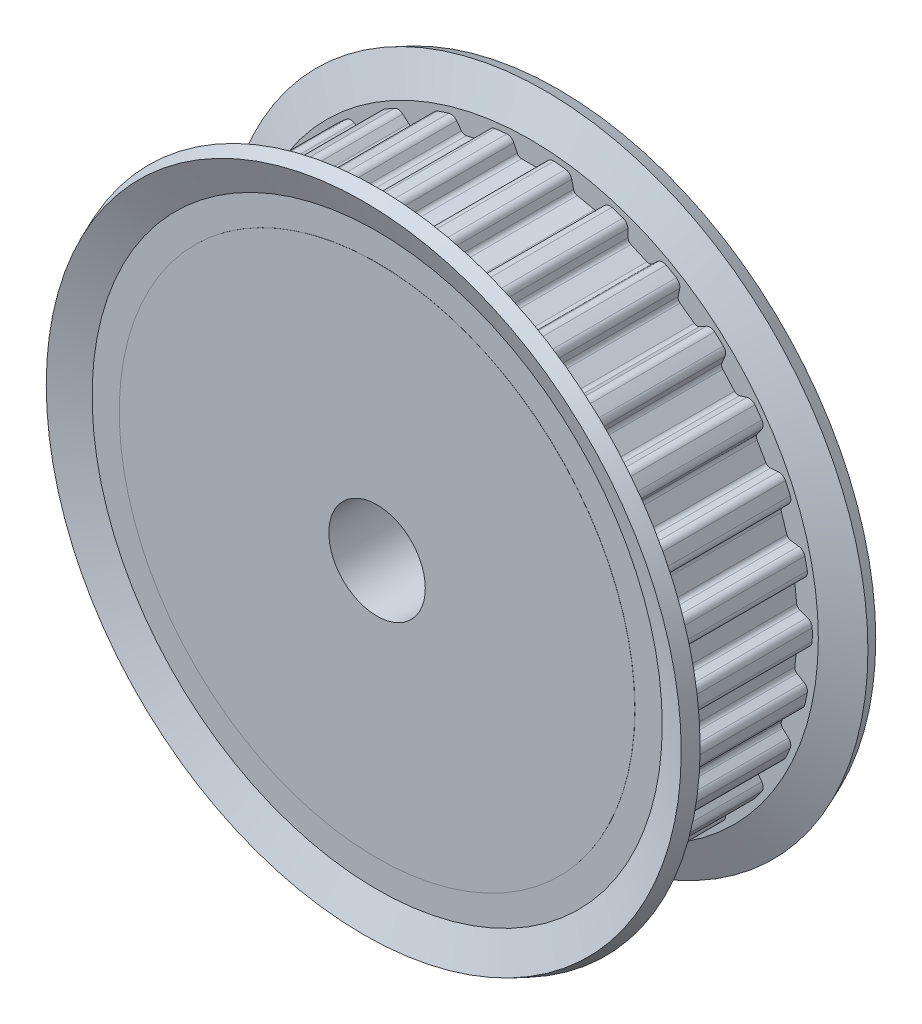
from build123d import *

# Parameters (mm, degrees)
TOOTHEXTRUDECUTGEARBELT01_DEPTH = 5.749999914
PATTERNGEARBELT01_COUNT         = 30
BOREREVOLVESKETCH_W             = 13.91999979
BOREREVOLVESKETCH_H             = 4


with BuildPart() as part:
    # SketchRevolveGearBelt01 → GearBelt01 (revolve)
    with BuildSketch(Plane(origin=(0, 0, 0), x_dir=(0, 0, -1), z_dir=(1, 0, 0))):
        Polygon((6.959999895, 0), (6.959999895, 21.373241143), (6.949999896, 21.373241143), (6.949999896, 23.634546268), (8.063312621, 26.32232095), (6.954657199, 26.781541062), (5.749999914, 23.873241105), (5.749999914, 23.373242113), (-5.749999914, 23.373242113), (-5.749999914, 23.873241105), (-6.954657199, 26.781541062), (-8.063312621, 26.32232095), (-6.949999896, 23.634546268), (-6.949999896, 21.373241143), (-6.959999895, 21.373241143), (-6.959999895, 0), align=None)
    revolve(axis=Axis((0, 0, 0), (0, 0, -1)))

    # SketchToothGearBelt01 → ToothExtrudeCutGearBelt01 (cut, symmetric)
    with BuildSketch(Plane.XY):
        with BuildLine():
            Line((-1.365692178, 22.946619557), (-1.089439988, 22.354194823))
            ThreePointArc((-1.089439988, 22.354194823), (-0.941836719, 22.185885552), (-0.726916879, 22.123242132))
            Line((-0.726916879, 22.123242132), (0.726916879, 22.123242132))
            ThreePointArc((0.726916879, 22.123242132), (0.941836719, 22.185885552), (1.089439988, 22.354194823))
            Line((1.089439988, 22.354194823), (1.365692178, 22.946619557))
            ThreePointArc((1.365692178, 22.946619557), (1.608614565, 23.212165045), (1.959785274, 23.290935759))
            Line((1.959785274, 23.290935759), (0, 25.830935721))
            Line((0, 25.830935721), (-1.959785274, 23.290935759))
            ThreePointArc((-1.959785274, 23.290935759), (-1.608614565, 23.212165045), (-1.365692178, 22.946619557))
        make_face()
    toothextrudecutgearbelt01 = extrude(amount=TOOTHEXTRUDECUTGEARBELT01_DEPTH, both=True, mode=Mode.SUBTRACT)

    # PatternGearBelt01: ToothExtrudeCutGearBelt01 ×30 about axis
    patterngearbelt01_axis = Axis((0, 0, 55), (0, 0, -1))
    for i in range(1, PATTERNGEARBELT01_COUNT):
        add(toothextrudecutgearbelt01.rotate(patterngearbelt01_axis, i * 360 / PATTERNGEARBELT01_COUNT), mode=Mode.SUBTRACT)

    # BoreRevolveSketch → BoreRevolveCut (revolve, cut)
    with BuildSketch(Plane(origin=(0, 0, 0), x_dir=(0, 0, -1), z_dir=(1, 0, 0))):
        with Locations((0, 2)):
            Rectangle(BOREREVOLVESKETCH_W, BOREREVOLVESKETCH_H)
    revolve(axis=Axis((0, 0, 0), (0, 0, -1)), mode=Mode.SUBTRACT)


solid = part.part
